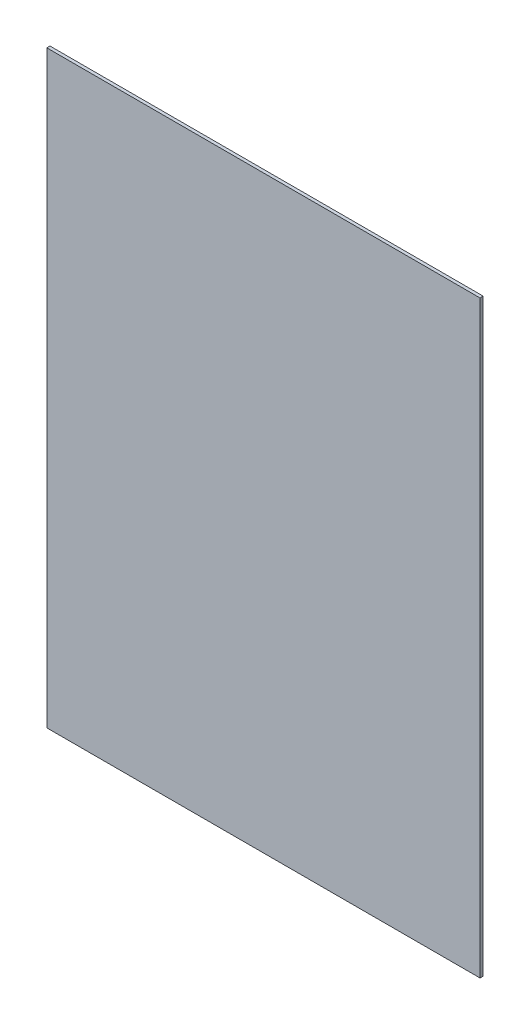
from build123d import *

# Parameters (mm, degrees)
SKETCH1_W           = 687
SKETCH1_H           = 934
BOSS_EXTRUDE1_DEPTH = 5


with BuildPart() as part:
    # Sketch1 → Boss-Extrude1 (new body)
    with BuildSketch(Plane.XY):
        with Locations((343.5, 467)):
            Rectangle(SKETCH1_W, SKETCH1_H)
    extrude(amount=BOSS_EXTRUDE1_DEPTH)


solid = part.part
